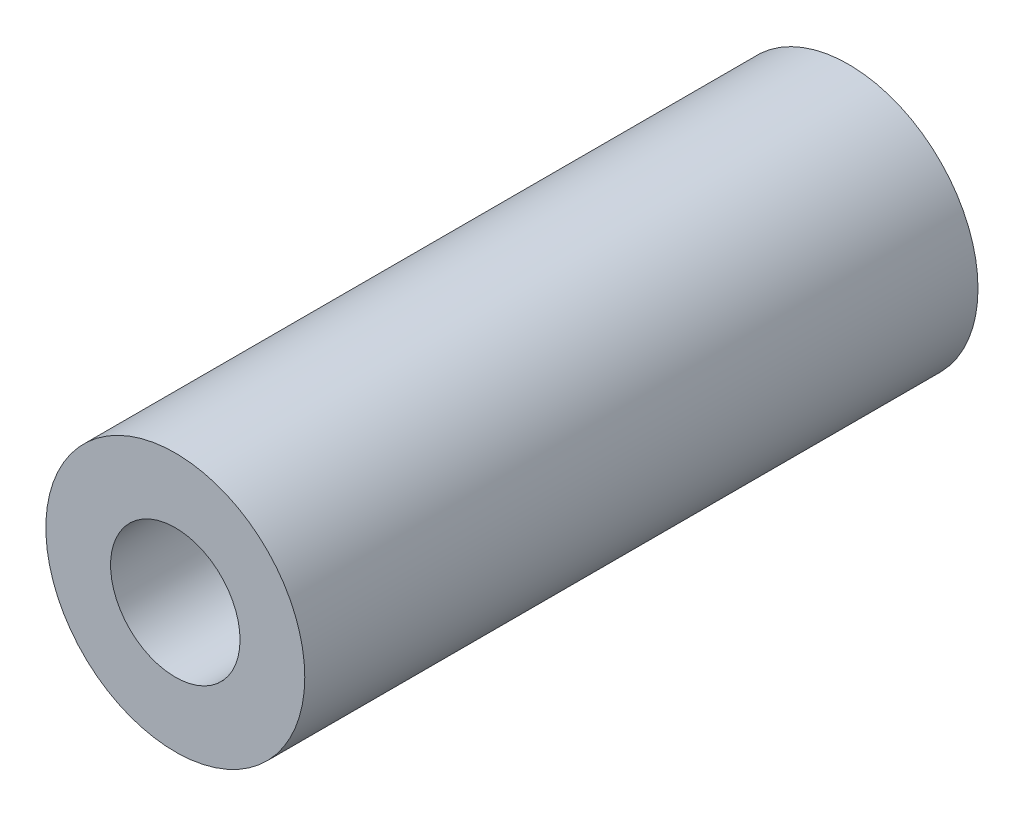
from build123d import *

# Parameters (mm, degrees)
ESQUISSE1_R        = 2.5
ESQUISSE1_R_2      = 1.25
BOSS_EXTRU_1_DEPTH = 13


with BuildPart() as part:
    # Esquisse1 → Boss.-Extru.1 (new body)
    with BuildSketch(Plane.XY):
        Circle(ESQUISSE1_R)
        Circle(ESQUISSE1_R_2, mode=Mode.SUBTRACT)
    extrude(amount=BOSS_EXTRU_1_DEPTH)


solid = part.part
